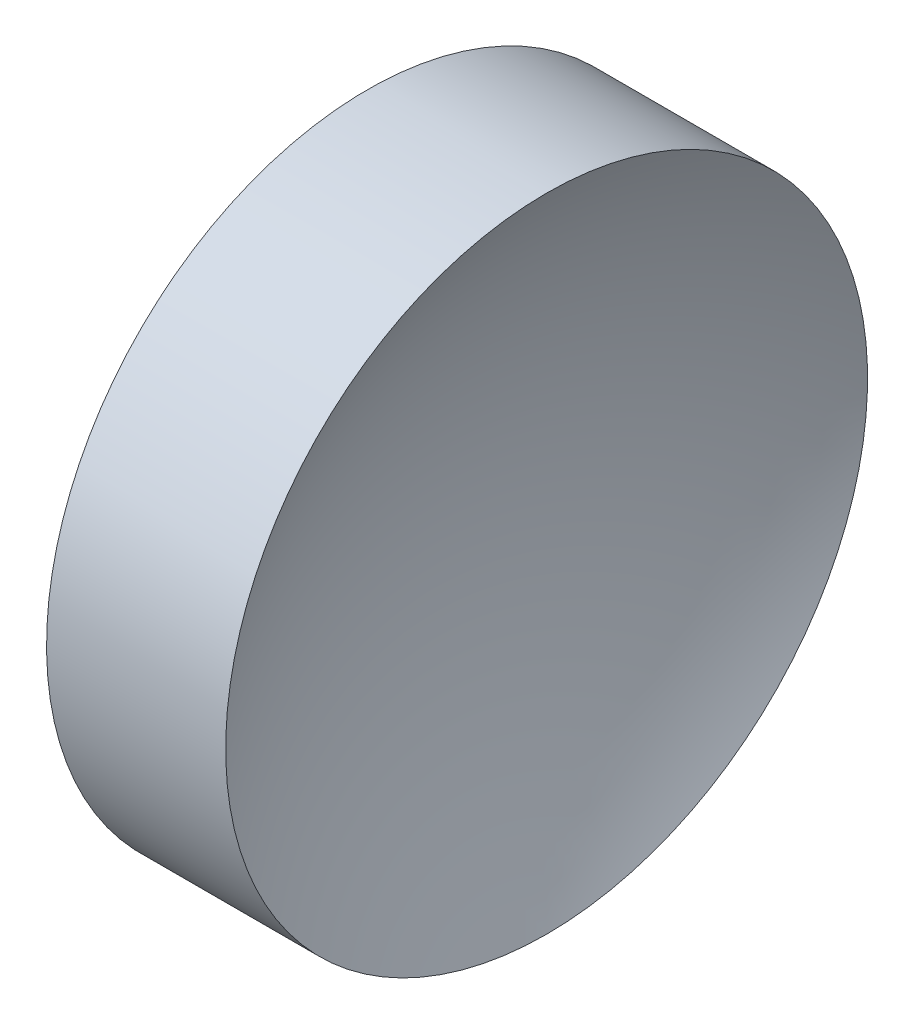
from build123d import *


with BuildPart() as part:
    # 草图1 → 旋转1 (revolve)
    with BuildSketch(Plane.XY):
        with BuildLine():
            Line((22.424232054, 13.031126091), (22.424232054, 18.031126091))
            Line((22.424232054, 18.031126091), (25.214934515, 18.031126091))
            ThreePointArc((25.214934515, 18.031126091), (24.252111189, 15.613078494), (23.924232054, 13.031126091))
            Line((23.924232054, 13.031126091), (22.424232054, 13.031126091))
        make_face()
    revolve(axis=Axis((21.505975118, 13.031126091, 0), (1, 0, 0)))


solid = part.part
